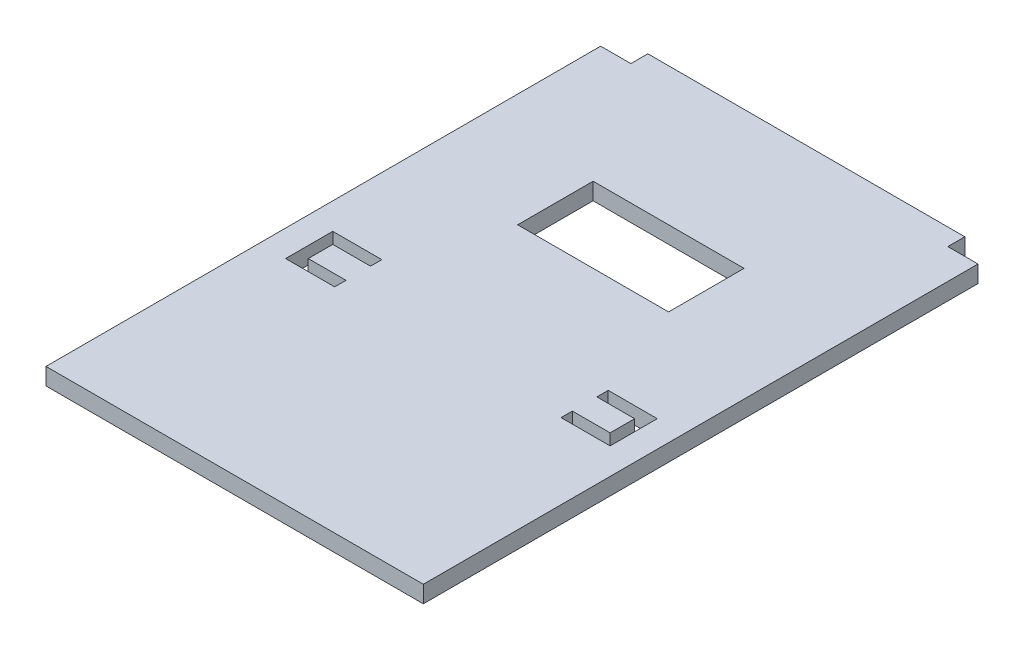
from build123d import *

# Parameters (mm, degrees)
SKETCH2_W           = 40
SKETCH2_H           = 20
BOSS_EXTRUDE1_DEPTH = 4.5


with BuildPart() as part:
    # Sketch2 → Boss-Extrude1 (new body)
    with BuildSketch(Plane(origin=(0, 0, 0), x_dir=(1, 0, 0), z_dir=(0, 1, 0))):
        Polygon((-42, 73.5), (-42, 78), (42, 78), (42, 73.5), (50, 73.5), (50, -73.5), (-50, -73.5), (-50, 73.5), align=None)
        Polygon((-43, -4.5), (-43, -17), (-30, -17), (-30, -14), (-40, -14), (-40, -7.5), (-30, -7.5), (-30, -4.5), align=None, mode=Mode.SUBTRACT)
        Polygon((30, -17), (30, -14), (40, -14), (40, -7.5), (30, -7.5), (30, -4.5), (43, -4.5), (43, -17), align=None, mode=Mode.SUBTRACT)
        with Locations((0, 31.5)):
            Rectangle(SKETCH2_W, SKETCH2_H, mode=Mode.SUBTRACT)
    extrude(amount=BOSS_EXTRUDE1_DEPTH)


solid = part.part
